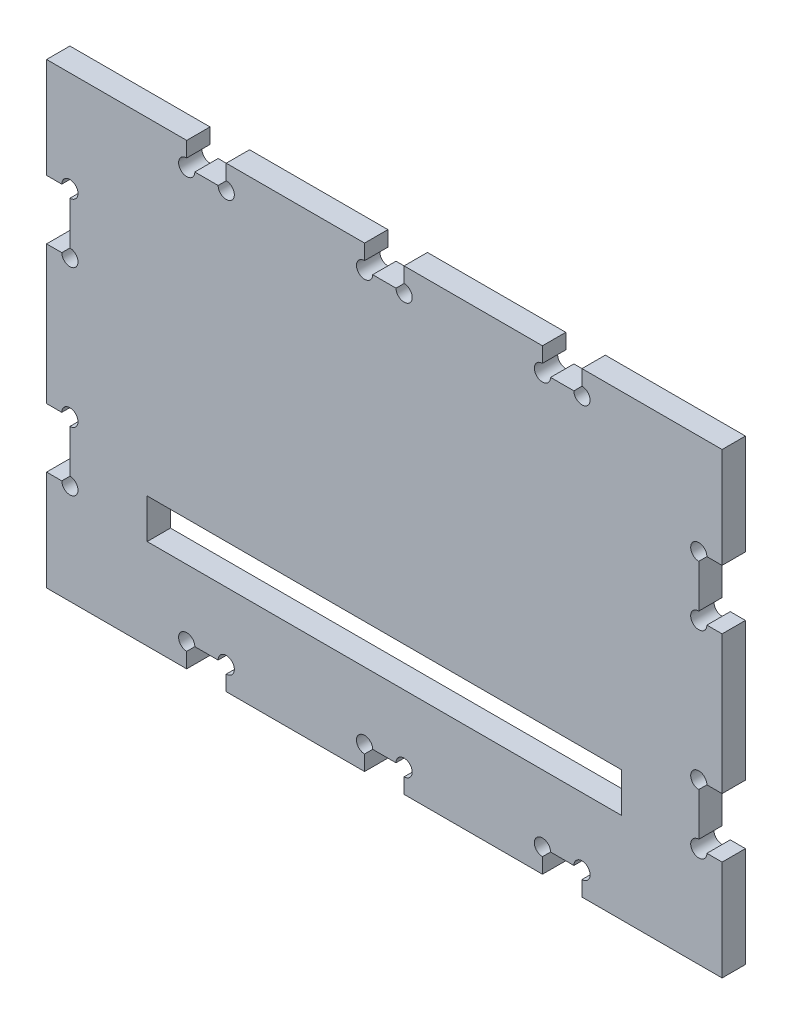
from build123d import *

# Parameters (mm, degrees)
SKETCH1_W           = 170.9
SKETCH1_H           = 115.79
BOSS_EXTRUDE1_DEPTH = 5.9
SKETCH2_W           = 5.9
SKETCH2_H           = 15
SKETCH2_W_2         = 10
SKETCH2_H_2         = 5.9
CUT_EXTRUDE1_DEPTH  = 6.9
CUT_EXTRUDE2_REACH  = 7.9
SKETCH4_W           = 120
SKETCH4_H           = 10
CUT_EXTRUDE3_REACH  = 7.9
SKETCH5_R           = 2.05


with BuildPart() as part:
    # Sketch1 → Boss-Extrude1 (new body)
    with BuildSketch(Plane.XY):
        Rectangle(SKETCH1_W, SKETCH1_H)
    extrude(amount=BOSS_EXTRUDE1_DEPTH)

    # Sketch2 → Cut-Extrude1 (cut, through all)
    with BuildSketch(Plane.XY.offset(5.9)):
        with Locations((-82.5, 25)):
            Rectangle(SKETCH2_W, SKETCH2_H)
        with Locations((-82.5, -25)):
            Rectangle(SKETCH2_W, SKETCH2_H)
        with Locations((82.5, -25)):
            Rectangle(SKETCH2_W, SKETCH2_H)
        with Locations((82.5, 25)):
            Rectangle(SKETCH2_W, SKETCH2_H)
        with Locations((-45, 54.945)):
            Rectangle(SKETCH2_W_2, SKETCH2_H_2)
        with Locations((0, 54.945)):
            Rectangle(SKETCH2_W_2, SKETCH2_H_2)
        with Locations((45, 54.945)):
            Rectangle(SKETCH2_W_2, SKETCH2_H_2)
        with Locations((45, -54.945)):
            Rectangle(SKETCH2_W_2, SKETCH2_H_2)
        with Locations((0, -54.945)):
            Rectangle(SKETCH2_W_2, SKETCH2_H_2)
        with Locations((-45, -54.945)):
            Rectangle(SKETCH2_W_2, SKETCH2_H_2)
    extrude(amount=-CUT_EXTRUDE1_DEPTH, mode=Mode.SUBTRACT)

    # Sketch4 → Cut-Extrude2 (cut, up to next)
    with BuildSketch(Plane.XY.offset(5.9), mode=Mode.PRIVATE) as cut_extrude2_sk1:
        with Locations((0, -30)):
            Rectangle(SKETCH4_W, SKETCH4_H)
    cut_extrude2_tool1 = extrude(cut_extrude2_sk1.sketch, amount=-CUT_EXTRUDE2_REACH, mode=Mode.PRIVATE) & part.part
    add(cut_extrude2_tool1.solids().sort_by_distance((0, -30, 5.9))[0], mode=Mode.SUBTRACT)

    # Sketch5 → Cut-Extrude3 (cut, up to next)
    with BuildSketch(Plane.XY.offset(5.9), mode=Mode.PRIVATE) as cut_extrude3_sk1:
        with Locations((-50, 51.995)):
            Circle(SKETCH5_R)
    cut_extrude3_tool1 = extrude(cut_extrude3_sk1.sketch, amount=-CUT_EXTRUDE3_REACH, mode=Mode.PRIVATE) & part.part
    add(cut_extrude3_tool1.solids().sort_by_distance((-50, 51.995, 5.9))[0], mode=Mode.SUBTRACT)
    # Sketch5 → Cut-Extrude3 (cut, up to next)
    with BuildSketch(Plane.XY.offset(5.9), mode=Mode.PRIVATE) as cut_extrude3_sk2:
        with Locations((-40, 51.995)):
            Circle(SKETCH5_R)
    cut_extrude3_tool2 = extrude(cut_extrude3_sk2.sketch, amount=-CUT_EXTRUDE3_REACH, mode=Mode.PRIVATE) & part.part
    add(cut_extrude3_tool2.solids().sort_by_distance((-40, 51.995, 5.9))[0], mode=Mode.SUBTRACT)
    # Sketch5 → Cut-Extrude3 (cut, up to next)
    with BuildSketch(Plane.XY.offset(5.9), mode=Mode.PRIVATE) as cut_extrude3_sk3:
        with Locations((-5, 51.995)):
            Circle(SKETCH5_R)
    cut_extrude3_tool3 = extrude(cut_extrude3_sk3.sketch, amount=-CUT_EXTRUDE3_REACH, mode=Mode.PRIVATE) & part.part
    add(cut_extrude3_tool3.solids().sort_by_distance((-5, 51.995, 5.9))[0], mode=Mode.SUBTRACT)
    # Sketch5 → Cut-Extrude3 (cut, up to next)
    with BuildSketch(Plane.XY.offset(5.9), mode=Mode.PRIVATE) as cut_extrude3_sk4:
        with Locations((5, 51.995)):
            Circle(SKETCH5_R)
    cut_extrude3_tool4 = extrude(cut_extrude3_sk4.sketch, amount=-CUT_EXTRUDE3_REACH, mode=Mode.PRIVATE) & part.part
    add(cut_extrude3_tool4.solids().sort_by_distance((5, 51.995, 5.9))[0], mode=Mode.SUBTRACT)
    # Sketch5 → Cut-Extrude3 (cut, up to next)
    with BuildSketch(Plane.XY.offset(5.9), mode=Mode.PRIVATE) as cut_extrude3_sk5:
        with Locations((40, 51.995)):
            Circle(SKETCH5_R)
    cut_extrude3_tool5 = extrude(cut_extrude3_sk5.sketch, amount=-CUT_EXTRUDE3_REACH, mode=Mode.PRIVATE) & part.part
    add(cut_extrude3_tool5.solids().sort_by_distance((40, 51.995, 5.9))[0], mode=Mode.SUBTRACT)
    # Sketch5 → Cut-Extrude3 (cut, up to next)
    with BuildSketch(Plane.XY.offset(5.9), mode=Mode.PRIVATE) as cut_extrude3_sk6:
        with Locations((50, 51.995)):
            Circle(SKETCH5_R)
    cut_extrude3_tool6 = extrude(cut_extrude3_sk6.sketch, amount=-CUT_EXTRUDE3_REACH, mode=Mode.PRIVATE) & part.part
    add(cut_extrude3_tool6.solids().sort_by_distance((50, 51.995, 5.9))[0], mode=Mode.SUBTRACT)
    # Sketch5 → Cut-Extrude3 (cut, up to next)
    with BuildSketch(Plane.XY.offset(5.9), mode=Mode.PRIVATE) as cut_extrude3_sk7:
        with Locations((79.55, 32.5)):
            Circle(SKETCH5_R)
    cut_extrude3_tool7 = extrude(cut_extrude3_sk7.sketch, amount=-CUT_EXTRUDE3_REACH, mode=Mode.PRIVATE) & part.part
    add(cut_extrude3_tool7.solids().sort_by_distance((79.55, 32.5, 5.9))[0], mode=Mode.SUBTRACT)
    # Sketch5 → Cut-Extrude3 (cut, up to next)
    with BuildSketch(Plane.XY.offset(5.9), mode=Mode.PRIVATE) as cut_extrude3_sk8:
        with Locations((79.55, 17.5)):
            Circle(SKETCH5_R)
    cut_extrude3_tool8 = extrude(cut_extrude3_sk8.sketch, amount=-CUT_EXTRUDE3_REACH, mode=Mode.PRIVATE) & part.part
    add(cut_extrude3_tool8.solids().sort_by_distance((79.55, 17.5, 5.9))[0], mode=Mode.SUBTRACT)
    # Sketch5 → Cut-Extrude3 (cut, up to next)
    with BuildSketch(Plane.XY.offset(5.9), mode=Mode.PRIVATE) as cut_extrude3_sk9:
        with Locations((79.55, -17.5)):
            Circle(SKETCH5_R)
    cut_extrude3_tool9 = extrude(cut_extrude3_sk9.sketch, amount=-CUT_EXTRUDE3_REACH, mode=Mode.PRIVATE) & part.part
    add(cut_extrude3_tool9.solids().sort_by_distance((79.55, -17.5, 5.9))[0], mode=Mode.SUBTRACT)
    # Sketch5 → Cut-Extrude3 (cut, up to next)
    with BuildSketch(Plane.XY.offset(5.9), mode=Mode.PRIVATE) as cut_extrude3_sk10:
        with Locations((79.55, -32.5)):
            Circle(SKETCH5_R)
    cut_extrude3_tool10 = extrude(cut_extrude3_sk10.sketch, amount=-CUT_EXTRUDE3_REACH, mode=Mode.PRIVATE) & part.part
    add(cut_extrude3_tool10.solids().sort_by_distance((79.55, -32.5, 5.9))[0], mode=Mode.SUBTRACT)
    # Sketch5 → Cut-Extrude3 (cut, up to next)
    with BuildSketch(Plane.XY.offset(5.9), mode=Mode.PRIVATE) as cut_extrude3_sk11:
        with Locations((-40, -51.995)):
            Circle(SKETCH5_R)
    cut_extrude3_tool11 = extrude(cut_extrude3_sk11.sketch, amount=-CUT_EXTRUDE3_REACH, mode=Mode.PRIVATE) & part.part
    add(cut_extrude3_tool11.solids().sort_by_distance((-40, -51.995, 5.9))[0], mode=Mode.SUBTRACT)
    # Sketch5 → Cut-Extrude3 (cut, up to next)
    with BuildSketch(Plane.XY.offset(5.9), mode=Mode.PRIVATE) as cut_extrude3_sk12:
        with Locations((-5, -51.995)):
            Circle(SKETCH5_R)
    cut_extrude3_tool12 = extrude(cut_extrude3_sk12.sketch, amount=-CUT_EXTRUDE3_REACH, mode=Mode.PRIVATE) & part.part
    add(cut_extrude3_tool12.solids().sort_by_distance((-5, -51.995, 5.9))[0], mode=Mode.SUBTRACT)
    # Sketch5 → Cut-Extrude3 (cut, up to next)
    with BuildSketch(Plane.XY.offset(5.9), mode=Mode.PRIVATE) as cut_extrude3_sk13:
        with Locations((5, -51.995)):
            Circle(SKETCH5_R)
    cut_extrude3_tool13 = extrude(cut_extrude3_sk13.sketch, amount=-CUT_EXTRUDE3_REACH, mode=Mode.PRIVATE) & part.part
    add(cut_extrude3_tool13.solids().sort_by_distance((5, -51.995, 5.9))[0], mode=Mode.SUBTRACT)
    # Sketch5 → Cut-Extrude3 (cut, up to next)
    with BuildSketch(Plane.XY.offset(5.9), mode=Mode.PRIVATE) as cut_extrude3_sk14:
        with Locations((40, -51.995)):
            Circle(SKETCH5_R)
    cut_extrude3_tool14 = extrude(cut_extrude3_sk14.sketch, amount=-CUT_EXTRUDE3_REACH, mode=Mode.PRIVATE) & part.part
    add(cut_extrude3_tool14.solids().sort_by_distance((40, -51.995, 5.9))[0], mode=Mode.SUBTRACT)
    # Sketch5 → Cut-Extrude3 (cut, up to next)
    with BuildSketch(Plane.XY.offset(5.9), mode=Mode.PRIVATE) as cut_extrude3_sk15:
        with Locations((50, -51.995)):
            Circle(SKETCH5_R)
    cut_extrude3_tool15 = extrude(cut_extrude3_sk15.sketch, amount=-CUT_EXTRUDE3_REACH, mode=Mode.PRIVATE) & part.part
    add(cut_extrude3_tool15.solids().sort_by_distance((50, -51.995, 5.9))[0], mode=Mode.SUBTRACT)
    # Sketch5 → Cut-Extrude3 (cut, up to next)
    with BuildSketch(Plane.XY.offset(5.9), mode=Mode.PRIVATE) as cut_extrude3_sk16:
        with Locations((-50, -51.995)):
            Circle(SKETCH5_R)
    cut_extrude3_tool16 = extrude(cut_extrude3_sk16.sketch, amount=-CUT_EXTRUDE3_REACH, mode=Mode.PRIVATE) & part.part
    add(cut_extrude3_tool16.solids().sort_by_distance((-50, -51.995, 5.9))[0], mode=Mode.SUBTRACT)
    # Sketch5 → Cut-Extrude3 (cut, up to next)
    with BuildSketch(Plane.XY.offset(5.9), mode=Mode.PRIVATE) as cut_extrude3_sk17:
        with Locations((-79.55, -32.5)):
            Circle(SKETCH5_R)
    cut_extrude3_tool17 = extrude(cut_extrude3_sk17.sketch, amount=-CUT_EXTRUDE3_REACH, mode=Mode.PRIVATE) & part.part
    add(cut_extrude3_tool17.solids().sort_by_distance((-79.55, -32.5, 5.9))[0], mode=Mode.SUBTRACT)
    # Sketch5 → Cut-Extrude3 (cut, up to next)
    with BuildSketch(Plane.XY.offset(5.9), mode=Mode.PRIVATE) as cut_extrude3_sk18:
        with Locations((-79.55, -17.5)):
            Circle(SKETCH5_R)
    cut_extrude3_tool18 = extrude(cut_extrude3_sk18.sketch, amount=-CUT_EXTRUDE3_REACH, mode=Mode.PRIVATE) & part.part
    add(cut_extrude3_tool18.solids().sort_by_distance((-79.55, -17.5, 5.9))[0], mode=Mode.SUBTRACT)
    # Sketch5 → Cut-Extrude3 (cut, up to next)
    with BuildSketch(Plane.XY.offset(5.9), mode=Mode.PRIVATE) as cut_extrude3_sk19:
        with Locations((-79.55, 17.5)):
            Circle(SKETCH5_R)
    cut_extrude3_tool19 = extrude(cut_extrude3_sk19.sketch, amount=-CUT_EXTRUDE3_REACH, mode=Mode.PRIVATE) & part.part
    add(cut_extrude3_tool19.solids().sort_by_distance((-79.55, 17.5, 5.9))[0], mode=Mode.SUBTRACT)
    # Sketch5 → Cut-Extrude3 (cut, up to next)
    with BuildSketch(Plane.XY.offset(5.9), mode=Mode.PRIVATE) as cut_extrude3_sk20:
        with Locations((-79.55, 32.5)):
            Circle(SKETCH5_R)
    cut_extrude3_tool20 = extrude(cut_extrude3_sk20.sketch, amount=-CUT_EXTRUDE3_REACH, mode=Mode.PRIVATE) & part.part
    add(cut_extrude3_tool20.solids().sort_by_distance((-79.55, 32.5, 5.9))[0], mode=Mode.SUBTRACT)


solid = part.part
